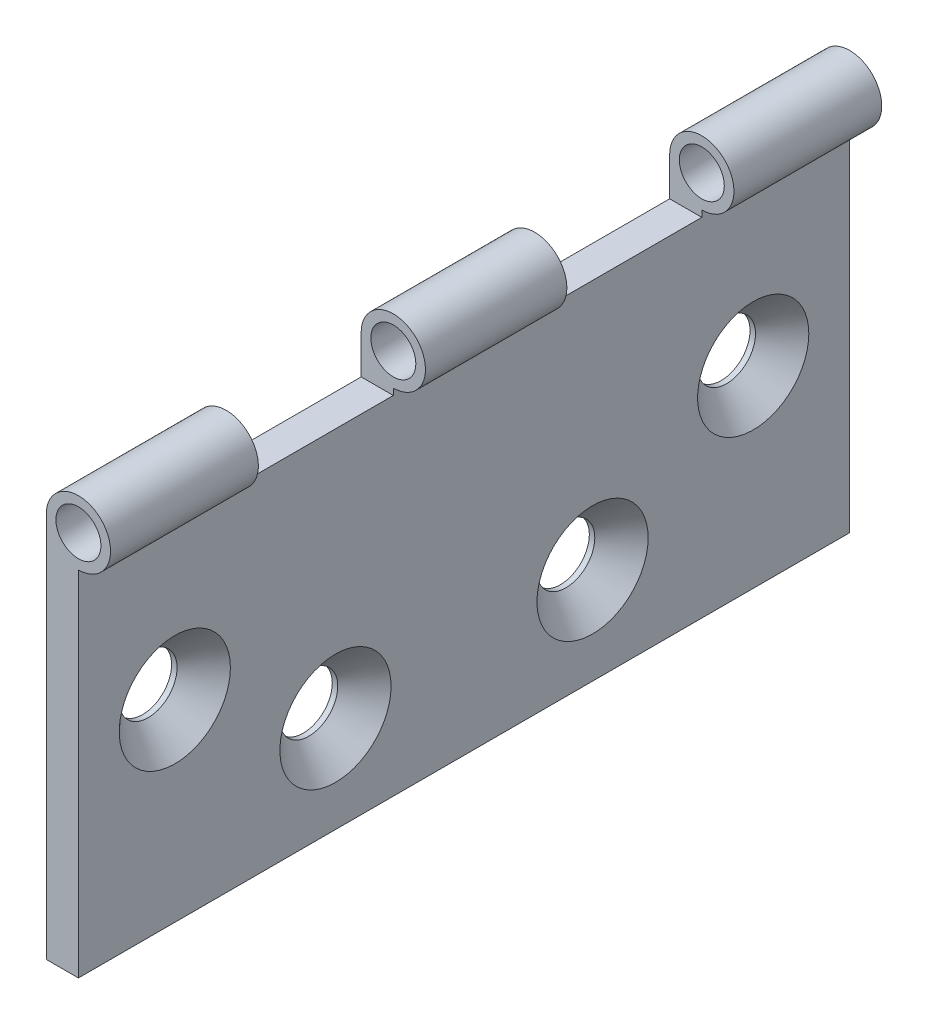
from build123d import *

# Parameters (mm, degrees)
SKETCH15_W                                     = 5
SKETCH15_H                                     = 60
EXTRUDE_THIN2_DEPTH                            = 60
SKETCH16_R                                     = 5
SKETCH17_R                                     = 3.5
CUT_EXTRUDE4_DEPTH                             = 137.839321834
CSK_FOR_M8_FLAT_HEAD_MACHINE_SCREW4_AT_2_COUNT = 2
CSK_FOR_M8_FLAT_HEAD_MACHINE_SCREW4_AT_2_PITCH = 29.154759474
SKETCH37_W                                     = 26
SKETCH37_H                                     = 11
F_2CUTS_DEPTH                                  = 89.600225733
F_2CUTS_DEPTH_BACK                             = 89.600225733


with BuildPart() as part:
    # Sketch15 → Extrude-Thin2 (new, symmetric)
    with BuildSketch(Plane.XY):
        with Locations((2.5, 30)):
            Rectangle(SKETCH15_W, SKETCH15_H)
    extrude(amount=EXTRUDE_THIN2_DEPTH, both=True)

    # Sweep2: sweep along a curve in space
    with BuildLine() as sweep2_path:
        Line((5, 60, 60), (5, 60, -60))
    # Sketch16 → Sweep2 (sweep)
    with BuildSketch(Plane(origin=(0, 0, -60), x_dir=(-1, 0, 0), z_dir=(0, 0, -1))):
        with Locations((-5, 60)):
            Circle(SKETCH16_R)
    sweep(path=sweep2_path.line)

    # Sketch17 → Cut-Extrude4 (cut, through all)
    with BuildSketch(Plane.XY.offset(60)):
        with Locations((5, 60)):
            Circle(SKETCH17_R)
    extrude(amount=-CUT_EXTRUDE4_DEPTH, mode=Mode.SUBTRACT)

    # Sketch18 → CSK for M8 Flat Head Machine Screw4 (revolve, cut)
    with BuildSketch(Plane(origin=(5, 30, 45), x_dir=(0, 0, -1), z_dir=(0, 1, 0))):
        Polygon((0, 0), (0, 5), (4.5, 5), (4.5, 4.15), (8.65, 0), align=None)
    csk_for_m8_flat_head_machine_screw4 = revolve(axis=Axis((11.35, 30, 45), (-1, 0, 0)), mode=Mode.SUBTRACT)

    # CSK for M8 Flat Head Machine Screw4 at 2: CSK for M8 Flat Head Machine Screw4 ×2
    with Locations(*[Vector(0, -0.5144957554275265, -0.8574929257125442) * (i * CSK_FOR_M8_FLAT_HEAD_MACHINE_SCREW4_AT_2_PITCH) for i in range(1, CSK_FOR_M8_FLAT_HEAD_MACHINE_SCREW4_AT_2_COUNT)]):
        add(csk_for_m8_flat_head_machine_screw4, mode=Mode.SUBTRACT)

    # Mirror7: CSK for M8 Flat Head Machine Screw4 across plane
    add(csk_for_m8_flat_head_machine_screw4.mirror(Plane.XY), mode=Mode.SUBTRACT)

    # Mirror7 copy 1 sketch → Mirror7 copy 1 (revolve, cut)
    with BuildSketch(Plane(origin=(5, 15, -20), x_dir=(0, 0, 1), z_dir=(0, 1, 0))):
        Polygon((0, 0), (0, -5), (4.5, -5), (4.5, -4.15), (8.65, 0), align=None)
    revolve(axis=Axis((11.35, 15, -20), (1, 0, 0)), mode=Mode.SUBTRACT)

    # Sketch37 → 2Cuts (cut, two sides)
    with BuildSketch(Plane(origin=(5, 0, 0), x_dir=(0, 0, -1), z_dir=(1, 0, 0))) as f_2cuts_sk:
        with Locations((24, 59.5)):
            Rectangle(SKETCH37_W, SKETCH37_H)
        with Locations((-24, 59.5)):
            Rectangle(SKETCH37_W, SKETCH37_H)
    extrude(amount=F_2CUTS_DEPTH, mode=Mode.SUBTRACT)
    extrude(f_2cuts_sk.sketch, amount=-F_2CUTS_DEPTH_BACK, mode=Mode.SUBTRACT)


solid = part.part
